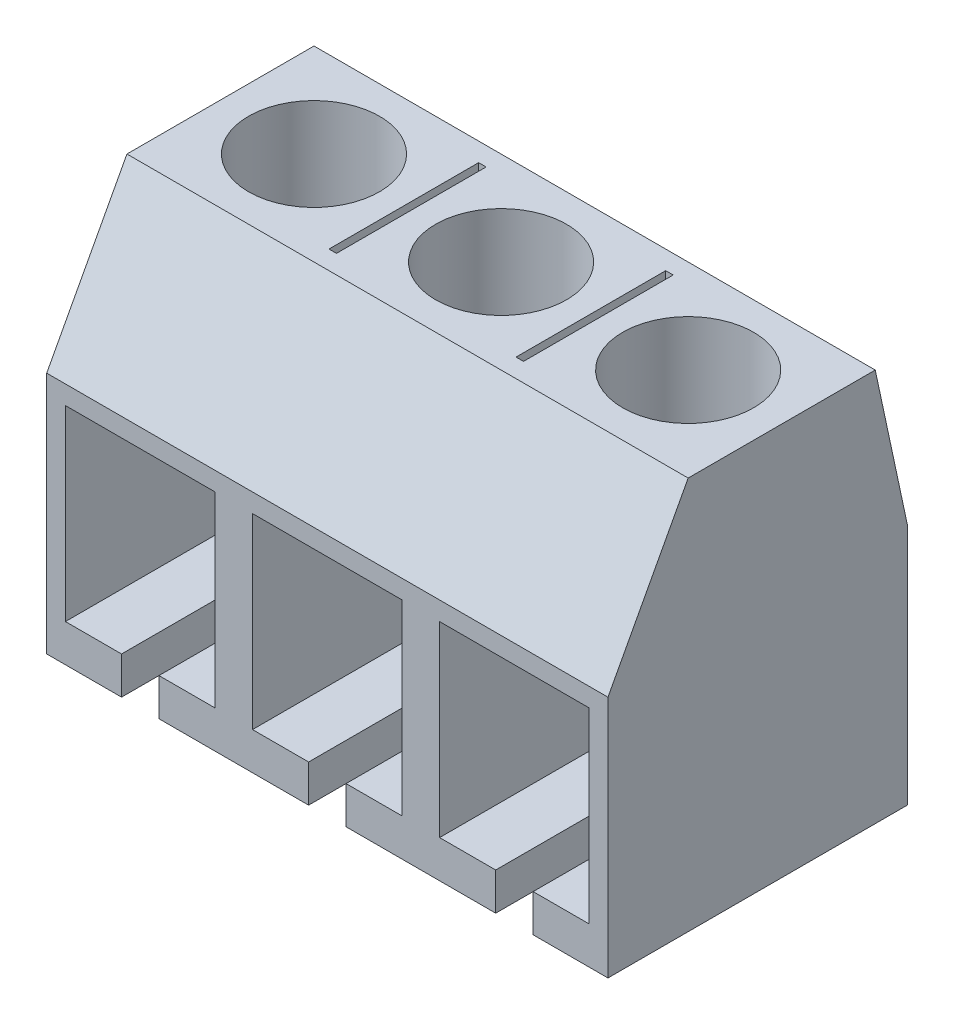
from build123d import *

# Parameters (mm, degrees)
Y_KSEKLIK_EKSTR_ZYON1_DEPTH      = 7.5
Y_KSEKLIK_EKSTR_ZYON1_DEPTH_BACK = 7.5
KES_EKSTR_ZYON1_DEPTH            = 13.267844146
IZIM3_R                          = 1.75
KES_EKSTR_ZYON2_DEPTH            = 7.5
IZIM4_W                          = 0.2
IZIM4_H                          = 4
KES_EKSTR_ZYON3_DEPTH            = 0.2


with BuildPart() as part:
    # Çizim1 → Yükseklik-Ekstrüzyon1 (new, two sides: drawn at the far end of the back side and taken through both)
    with BuildSketch(Plane(origin=(0, 0, 0), x_dir=(0, 0, -1), z_dir=(1, 0, 0)).offset(-Y_KSEKLIK_EKSTR_ZYON1_DEPTH_BACK)):
        Polygon((-1.856187291, 5), (3.143812709, 5), (4, 1), (4, -5.5), (-4, -5.5), (-4, 1), align=None)
    extrude(amount=Y_KSEKLIK_EKSTR_ZYON1_DEPTH + Y_KSEKLIK_EKSTR_ZYON1_DEPTH_BACK)

    # Çizim2 → Kes-Ekstrüzyon1 (cut, through all)
    with BuildSketch(Plane(origin=(0, 0, -4), x_dir=(-1, 0, 0), z_dir=(0, 0, -1))):
        Polygon((-0.5, -4.5), (-0.5, -5.5), (0.5, -5.5), (0.5, -4.5), (2, -4.5), (2, 0.5), (-2, 0.5), (-2, -4.5), align=None)
        Polygon((3, 0.5), (3, -4.5), (4.5, -4.5), (4.5, -5.5), (5.5, -5.5), (5.5, -4.5), (7, -4.5), (7, 0.5), align=None)
        Polygon((-7, 0.5), (-7, -4.5), (-5.5, -4.5), (-5.5, -5.5), (-4.5, -5.5), (-4.5, -4.5), (-3, -4.5), (-3, 0.5), align=None)
    extrude(amount=-KES_EKSTR_ZYON1_DEPTH, mode=Mode.SUBTRACT)

    # Çizim3 → Kes-Ekstrüzyon2 (cut)
    with BuildSketch(Plane(origin=(0, 5, 0), x_dir=(1, 0, 0), z_dir=(0, 1, 0))):
        with Locations((0, 0.643812709)):
            Circle(IZIM3_R)
        with Locations((-5, 0.643812709)):
            Circle(IZIM3_R)
        with Locations((5, 0.643812709)):
            Circle(IZIM3_R)
    extrude(amount=-KES_EKSTR_ZYON2_DEPTH, mode=Mode.SUBTRACT)

    # Çizim4 → Kes-Ekstrüzyon3 (cut)
    with BuildSketch(Plane(origin=(0, 5, 0), x_dir=(1, 0, 0), z_dir=(0, 1, 0))):
        with Locations((-2.5, 0.643812709)):
            Rectangle(IZIM4_W, IZIM4_H)
        with Locations((2.5, 0.643812709)):
            Rectangle(IZIM4_W, IZIM4_H)
    extrude(amount=-KES_EKSTR_ZYON3_DEPTH, mode=Mode.SUBTRACT)


solid = part.part
